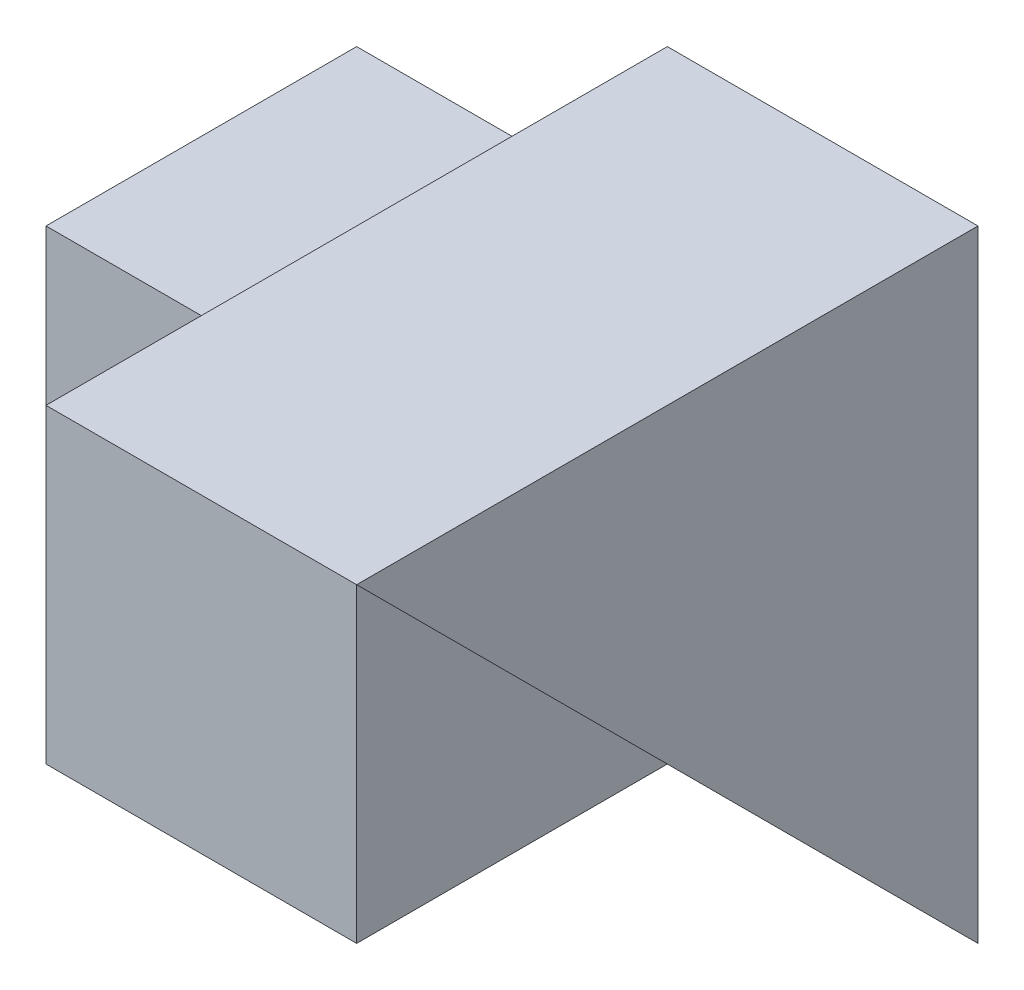
from build123d import *

# Parameters (mm, degrees)
SKETCH1_W           = 4
SKETCH1_H           = 4
BOSS_EXTRUDE1_DEPTH = 2
SKETCH2_W           = 2
SKETCH2_H           = 3
BOSS_EXTRUDE2_DEPTH = 2
CUT_EXTRUDE2_DEPTH  = 2


with BuildPart() as part:
    # Sketch1 → Boss-Extrude1 (new body)
    with BuildSketch(Plane(origin=(0, 0, 0), x_dir=(0, 0, -1), z_dir=(1, 0, 0))):
        with Locations((2, 2)):
            Rectangle(SKETCH1_W, SKETCH1_H)
    extrude(amount=BOSS_EXTRUDE1_DEPTH)

    # Sketch2 → Boss-Extrude2 (add)
    with BuildSketch(Plane.ZY):
        with Locations((-3, 1.5)):
            Rectangle(SKETCH2_W, SKETCH2_H)
    extrude(amount=BOSS_EXTRUDE2_DEPTH)

    # Sketch3 → Cut-Extrude2 (cut)
    with BuildSketch(Plane(origin=(2, 0, 0), x_dir=(0, 0, -1), z_dir=(1, 0, 0))):
        Polygon((0, 4), (4, 0), (0, 0), align=None)
    extrude(amount=-CUT_EXTRUDE2_DEPTH, mode=Mode.SUBTRACT)


solid = part.part
